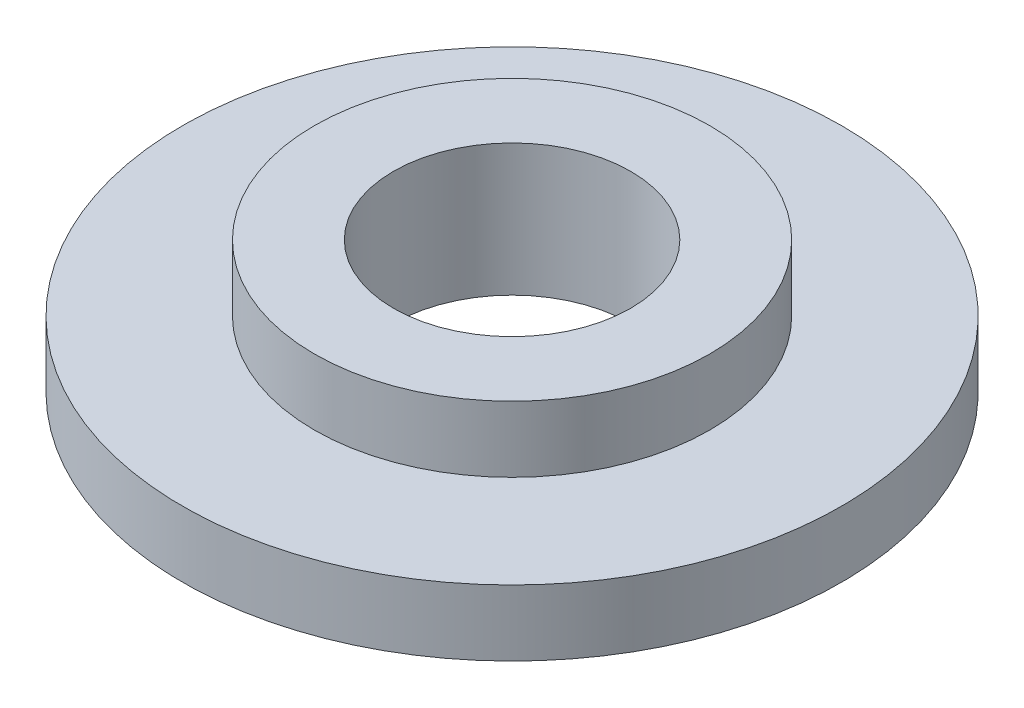
from build123d import *

# Parameters (mm, degrees)
SKETCH1_R           = 3
SKETCH1_R_2         = 1.8
BOSS_EXTRUDE1_DEPTH = 1
SKETCH2_R           = 5
SKETCH2_R_2         = 1.8
BOSS_EXTRUDE2_DEPTH = 1


with BuildPart() as part:
    # Sketch1 → Boss-Extrude1 (new body)
    with BuildSketch(Plane(origin=(0, 0, 0), x_dir=(1, 0, 0), z_dir=(0, 1, 0))):
        Circle(SKETCH1_R)
        Circle(SKETCH1_R_2, mode=Mode.SUBTRACT)
    extrude(amount=BOSS_EXTRUDE1_DEPTH)

    # Sketch2 → Boss-Extrude2 (add)
    with BuildSketch(Plane.XZ):
        Circle(SKETCH2_R)
        Circle(SKETCH2_R_2, mode=Mode.SUBTRACT)
    extrude(amount=BOSS_EXTRUDE2_DEPTH)


solid = part.part
